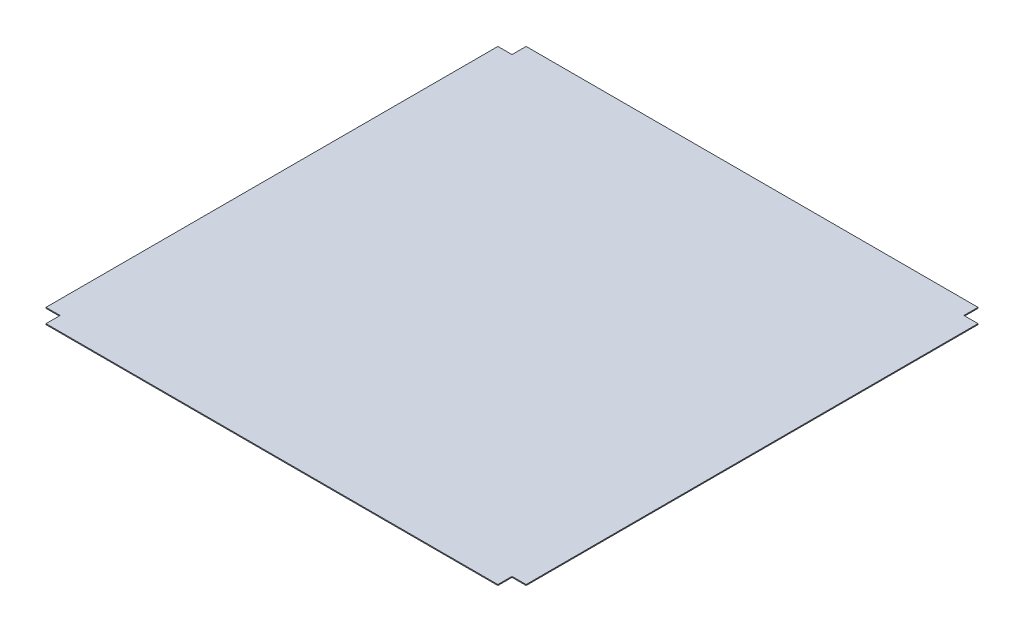
from build123d import *

# Parameters (mm, degrees)
SKETCH1_W          = 510
SKETCH1_H          = 510
EXTRUDE1_DEPTH     = 1
SKETCH3_W          = 15
SKETCH3_H          = 15
CUT_EXTRUDE1_DEPTH = 361.625844886


with BuildPart() as part:
    # Sketch1 → Extrude1 (new body)
    with BuildSketch(Plane(origin=(0, 0, 0), x_dir=(1, 0, 0), z_dir=(0, 1, 0))):
        Rectangle(SKETCH1_W, SKETCH1_H)
    extrude(amount=EXTRUDE1_DEPTH)

    # Sketch3 → Cut-Extrude1 (cut, through all)
    with BuildSketch(Plane(origin=(0, 1, 0), x_dir=(-1, 0, 0), z_dir=(0, 1, 0))):
        with Locations((-247.5, -247.5)):
            Rectangle(SKETCH3_W, SKETCH3_H)
        with Locations((-247.5, 247.5)):
            Rectangle(SKETCH3_W, SKETCH3_H)
        with Locations((247.5, 247.5)):
            Rectangle(SKETCH3_W, SKETCH3_H)
        with Locations((247.5, -247.5)):
            Rectangle(SKETCH3_W, SKETCH3_H)
    extrude(amount=-CUT_EXTRUDE1_DEPTH, mode=Mode.SUBTRACT)


solid = part.part
